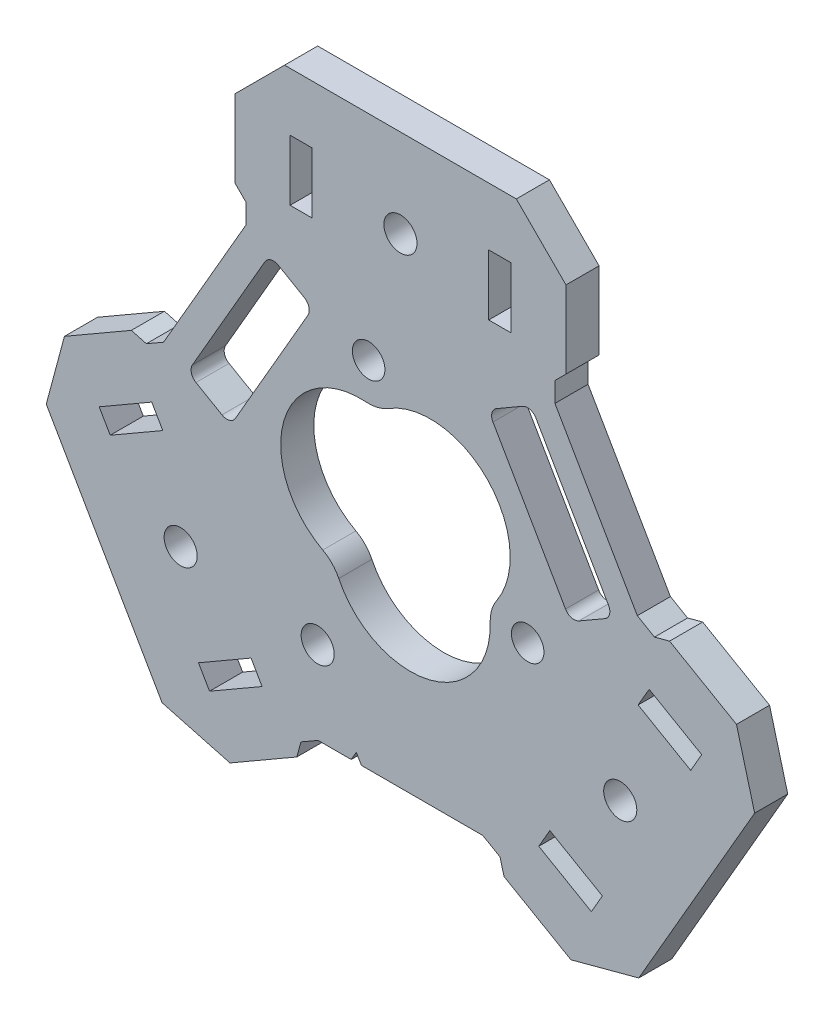
from build123d import *

# Parameters (mm, degrees)
SKETCH1_R           = 1.5
BOSS_EXTRUDE1_DEPTH = 3
SKETCH3_R           = 8.6
CUT_EXTRUDE2_DEPTH  = 45.723637698
SKETCH4_R           = 1.5
SKETCH4_R_2         = 1.475
CUT_EXTRUDE3_DEPTH  = 45.723637698
CUT_EXTRUDE4_DEPTH  = 45.723637698
CUT_EXTRUDE6_DEPTH  = 45.723637698
CUT_EXTRUDE7_DEPTH  = 45.723637698


with BuildPart() as part:
    # Sketch1 → Boss-Extrude1 (new body)
    with BuildSketch(Plane.XY):
        Polygon((0, -20.476245627), (7.465897773, -20.476245627), (9.02146997, -21.374355653), (9.387495374, -22.740381057), (11.136866689, -23.750381057), (15.4496732, -26.240381057), (21.596787517, -24.59326674), (32.096787517, -6.40673326), (30.4496732, -0.259618943), (26.136866689, 2.230381057), (24.387495374, 3.240381057), (23.02146997, 2.874355653), (21.465897773, 3.772465679), (17.732948887, 10.238122813), (14, 16.703779947), (14, 18.5), (15, 19.5), (15, 23), (15, 26.5), (10.5, 31), (-10.5, 31), (-15, 26.5), (-15, 23), (-15, 19.5), (-14, 18.5), (-14, 16.703779947), (-17.732948887, 10.238122813), (-21.465897773, 3.772465679), (-23.02146997, 2.874355653), (-24.387495374, 3.240381057), (-26.136866689, 2.230381057), (-30.4496732, -0.259618943), (-32.096787517, -6.40673326), (-21.596787517, -24.59326674), (-15.4496732, -26.240381057), (-11.136866689, -23.750381057), (-9.387495374, -22.740381057), (-9.02146997, -21.374355653), (-7.465897773, -20.476245627), align=None)
        with Locations((0, 23)):
            Circle(SKETCH1_R, mode=Mode.SUBTRACT)
        with Locations((19.918584287, -11.5)):
            Circle(SKETCH1_R, mode=Mode.SUBTRACT)
        with Locations((-19.918584287, -11.5)):
            Circle(SKETCH1_R, mode=Mode.SUBTRACT)
        Polygon((8, 23), (8, 25.75), (10, 25.75), (10, 23), (10, 20.25), (8, 20.25), align=None, mode=Mode.SUBTRACT)
        Polygon((12.537014427, -18.785254038), (13.636866689, -19.420254038), (17.300154147, -21.535254038), (18.300154147, -19.80320323), (15.918584287, -18.42820323), (13.537014427, -17.05320323), align=None, mode=Mode.SUBTRACT)
        Polygon((-8, 23), (-8, 20.25), (-10, 20.25), (-10, 23), (-10, 25.75), (-8, 25.75), align=None, mode=Mode.SUBTRACT)
        Polygon((27.300154147, -4.214745962), (23.636866689, -2.099745962), (22.537014427, -1.464745962), (21.537014427, -3.19679677), (23.918584287, -4.57179677), (26.300154147, -5.94679677), align=None, mode=Mode.SUBTRACT)
        Polygon((-22.537014427, -1.464745962), (-23.636866689, -2.099745962), (-27.300154147, -4.214745962), (-26.300154147, -5.94679677), (-23.918584287, -4.57179677), (-21.537014427, -3.19679677), align=None, mode=Mode.SUBTRACT)
        Polygon((-17.300154147, -21.535254038), (-13.636866689, -19.420254038), (-12.537014427, -18.785254038), (-13.537014427, -17.05320323), (-15.918584287, -18.42820323), (-18.300154147, -19.80320323), align=None, mode=Mode.SUBTRACT)
    extrude(amount=BOSS_EXTRUDE1_DEPTH)

    # Sketch3 → Cut-Extrude2 (cut, through all)
    with BuildSketch(Plane.XY.offset(3)):
        Circle(SKETCH3_R)
    extrude(amount=-CUT_EXTRUDE2_DEPTH, mode=Mode.SUBTRACT)

    # Sketch4 → Cut-Extrude3 (cut, through all)
    with BuildSketch(Plane.XY.offset(3)):
        with Locations((-7.5, -12.990381057)):
            Circle(SKETCH4_R)
        with Locations((-2.883414438, 11.648429988)):
            Circle(SKETCH4_R_2)
        with Locations((11.529543503, -3.327104841)):
            Circle(SKETCH4_R_2)
    extrude(amount=-CUT_EXTRUDE3_DEPTH, mode=Mode.SUBTRACT)

    # Sketch5 → Cut-Extrude4 (cut, through all)
    with BuildSketch(Plane.XY.offset(3)):
        with BuildLine():
            ThreePointArc((-5.590405789, -6.830501462), (-6.196392496, -5.963616355), (-7.039450485, -5.324896616))
            ThreePointArc((-7.039450485, -5.324896616), (-10.568748211, 3.049846104), (-3.120184892, 8.256684161))
            ThreePointArc((-3.120184892, 8.256684161), (-2.066447014, 8.348041491), (-1.0917705, 8.758791256))
            ThreePointArc((-1.0917705, 8.758791256), (7.925618309, 7.627881385), (8.710590681, -1.4261827))
            ThreePointArc((8.710590681, -1.4261827), (8.26283951, -2.384425136), (8.131220984, -3.433894641))
            ThreePointArc((8.131220984, -3.433894641), (2.643129902, -10.677727489), (-5.590405789, -6.830501462))
        make_face()
    extrude(amount=-CUT_EXTRUDE4_DEPTH, mode=Mode.SUBTRACT)

    # Sketch7 → Cut-Extrude6 (cut, through all)
    with BuildSketch(Plane.XY.offset(3)):
        with BuildLine():
            Line((12.279936491, 14.683017338), (18.855834264, 3.293228289))
            ThreePointArc((18.855834264, 3.293228289), (18.94474564, 2.617879339), (18.530071655, 2.077465679))
            Line((18.530071655, 2.077465679), (16.174482556, 0.717465679))
            ThreePointArc((16.174482556, 0.717465679), (15.499133606, 0.628554303), (14.958719947, 1.043228289))
            Line((14.958719947, 1.043228289), (8.382822174, 12.433017338))
            ThreePointArc((8.382822174, 12.433017338), (8.293910797, 13.108366288), (8.708584783, 13.648779947))
            Line((8.708584783, 13.648779947), (11.064173881, 15.008779947))
            ThreePointArc((11.064173881, 15.008779947), (11.739522831, 15.097691323), (12.279936491, 14.683017338))
        make_face()
        with BuildLine():
            Line((-12.279936491, 14.683017338), (-18.855834264, 3.293228289))
            ThreePointArc((-18.855834264, 3.293228289), (-18.94474564, 2.617879339), (-18.530071655, 2.077465679))
            Line((-18.530071655, 2.077465679), (-16.174482556, 0.717465679))
            ThreePointArc((-16.174482556, 0.717465679), (-15.499133606, 0.628554303), (-14.958719947, 1.043228289))
            Line((-14.958719947, 1.043228289), (-8.382822174, 12.433017338))
            ThreePointArc((-8.382822174, 12.433017338), (-8.293910797, 13.108366288), (-8.708584783, 13.648779947))
            Line((-8.708584783, 13.648779947), (-11.064173881, 15.008779947))
            ThreePointArc((-11.064173881, 15.008779947), (-11.739522831, 15.097691323), (-12.279936491, 14.683017338))
        make_face()
    extrude(amount=-CUT_EXTRUDE6_DEPTH, mode=Mode.SUBTRACT)

    # Sketch8 → Cut-Extrude7 (cut, through all)
    with BuildSketch(Plane.XY.offset(3)):
        Polygon((-3.538119785, -20.476245627), (-4, -19.676245627), (-4.461880215, -20.476245627), align=None)
    extrude(amount=-CUT_EXTRUDE7_DEPTH, mode=Mode.SUBTRACT)


solid = part.part
